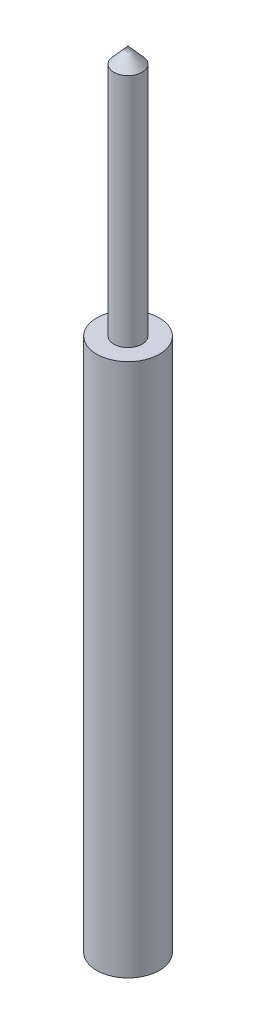
from build123d import *


with BuildPart() as part:
    # Esquisse1 → Révolution1 (revolve)
    with BuildSketch(Plane.XY):
        Polygon((0, 25), (0.45, 24.5), (0.45, 17), (1, 17), (1, 0), (0, 0), align=None)
    revolve(axis=Axis((0, 0, 0), (0, 1, 0)))


solid = part.part
